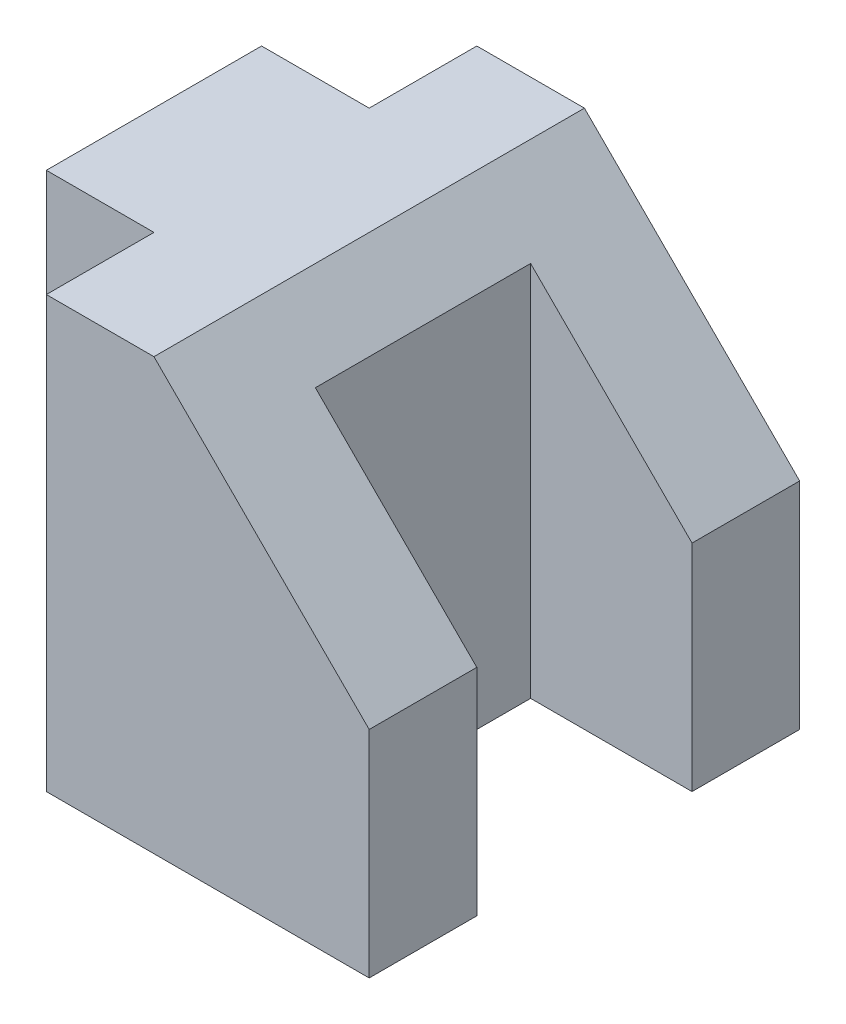
from build123d import *

# Parameters (mm, degrees)
BOSS_EXTRUDE1_DEPTH = 101.6
CUT_EXTRUDE2_DEPTH  = 102.6


with BuildPart() as part:
    # Sketch1 → Boss-Extrude1 (new body)
    with BuildSketch(Plane(origin=(0, 0, 0), x_dir=(1, 0, 0), z_dir=(0, 1, 0))):
        Polygon((0, 0), (-38.1, 0), (-38.1, 25.4), (-63.5, 25.4), (-63.5, 76.2), (-38.1, 76.2), (-38.1, 101.6), (38.1, 101.6), (38.1, 76.2), (0, 76.2), (0, 25.4), (38.1, 25.4), (38.1, 0), align=None)
    extrude(amount=BOSS_EXTRUDE1_DEPTH)

    # Sketch2 → Cut-Extrude2 (cut, through all)
    with BuildSketch(Plane.XY):
        Polygon((-12.7, 101.6), (38.1, 50.8), (38.1, 101.6), align=None)
    extrude(amount=-CUT_EXTRUDE2_DEPTH, mode=Mode.SUBTRACT)


solid = part.part
